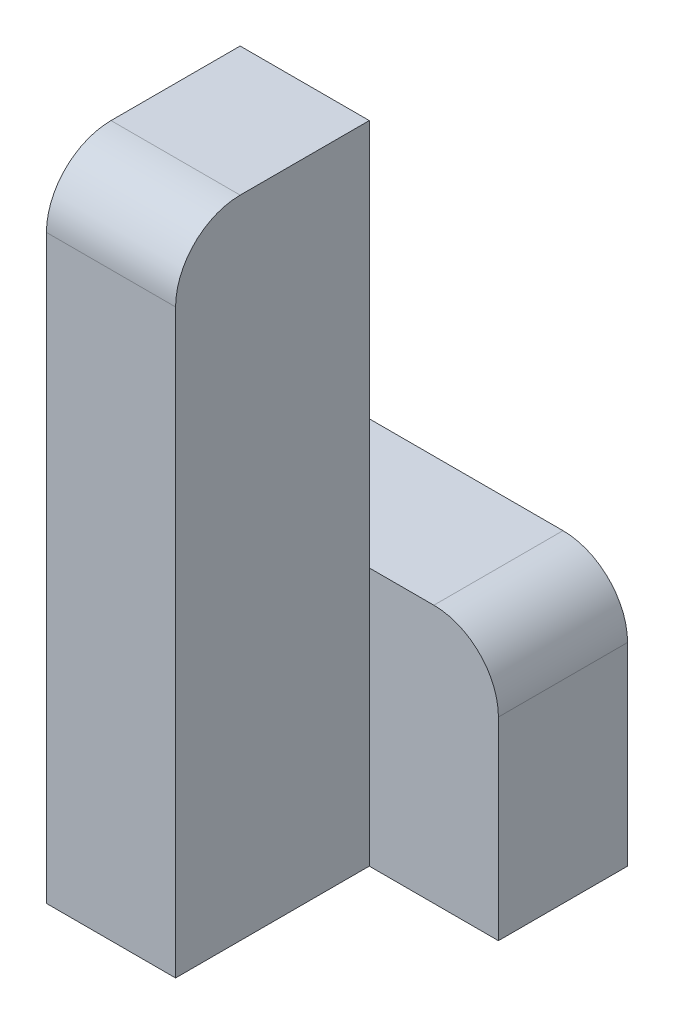
from build123d import *

# Parameters (mm, degrees)
SKETCH1_W           = 20
SKETCH1_H           = 100
BOSS_EXTRUDE1_DEPTH = 30
SKETCH2_W           = 40
SKETCH2_H           = 40
BOSS_EXTRUDE2_DEPTH = 20
FILLET1_R           = 10


with BuildPart() as part:
    # Sketch1 → Boss-Extrude1 (new body)
    with BuildSketch(Plane.XY):
        with Locations((-20, -50)):
            Rectangle(SKETCH1_W, SKETCH1_H)
    extrude(amount=BOSS_EXTRUDE1_DEPTH)

    # Sketch2 → Boss-Extrude2 (add)
    with BuildSketch(Plane.XY):
        with Locations((-10, -80)):
            Rectangle(SKETCH2_W, SKETCH2_H)
    extrude(amount=-BOSS_EXTRUDE2_DEPTH)

    # Fillet1
    fillet1_edges = [part.edges().sort_by_distance(p)[0] for p in [
        (10, -60, -10),
        (-20, 0, 30),
    ]]
    fillet(fillet1_edges, radius=FILLET1_R)


solid = part.part
